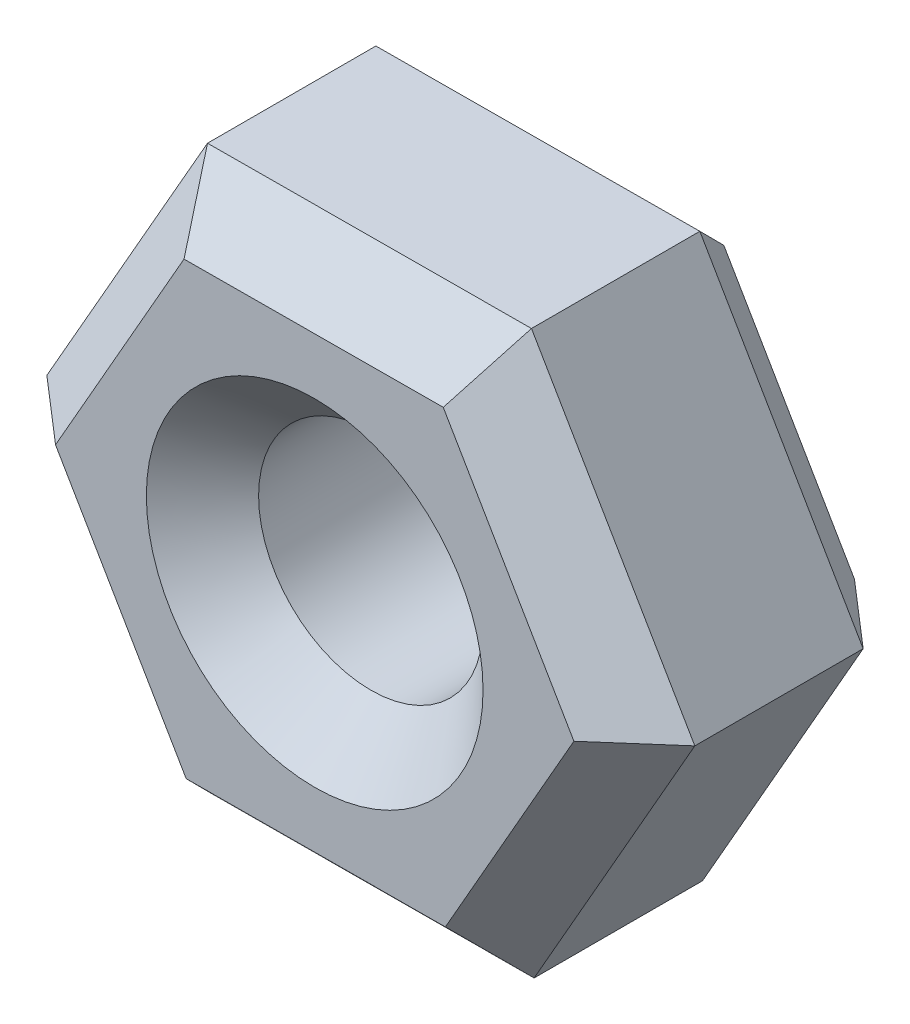
from build123d import *

# Parameters (mm, degrees)
SKETCH2_R           = 2
BOSS_EXTRUDE1_DEPTH = 5
CHAMFER2_SIZE       = 1


with BuildPart() as part:
    # Sketch2 → Boss-Extrude1 (new body)
    with BuildSketch(Plane.XY):
        Polygon((-33.204562103, 16.96373801), (-38.977999735, 16.936329175), (-41.840981804, 11.922681101), (-38.93052624, 6.936441863), (-33.157088608, 6.963850698), (-30.29410654, 11.977498771), align=None)
        with Locations((-36.067544172, 11.950089936)):
            Circle(SKETCH2_R, mode=Mode.SUBTRACT)
    extrude(amount=BOSS_EXTRUDE1_DEPTH)

    # Chamfer2
    chamfer2_edges = [part.edges().sort_by_distance(p)[0] for p in [
        (-40.409490769, 14.429505138, 5),
        (-40.385754022, 9.429561482, 5),
        (-38.067544172, 11.950089936, 0),
        (-38.067544172, 11.950089936, 5),
        (-36.043807424, 6.95014628, 5),
        (-31.725597574, 9.470674734, 5),
        (-31.749334322, 14.470618391, 5),
        (-31.725597574, 9.470674734, 0),
        (-36.043807424, 6.95014628, 0),
        (-40.385754022, 9.429561482, 0),
        (-40.409490769, 14.429505138, 0),
        (-36.091280919, 16.950033593, 0),
        (-31.749334322, 14.470618391, 0),
        (-36.091280919, 16.950033593, 5),
    ]]
    chamfer(chamfer2_edges, length=CHAMFER2_SIZE)


solid = part.part
